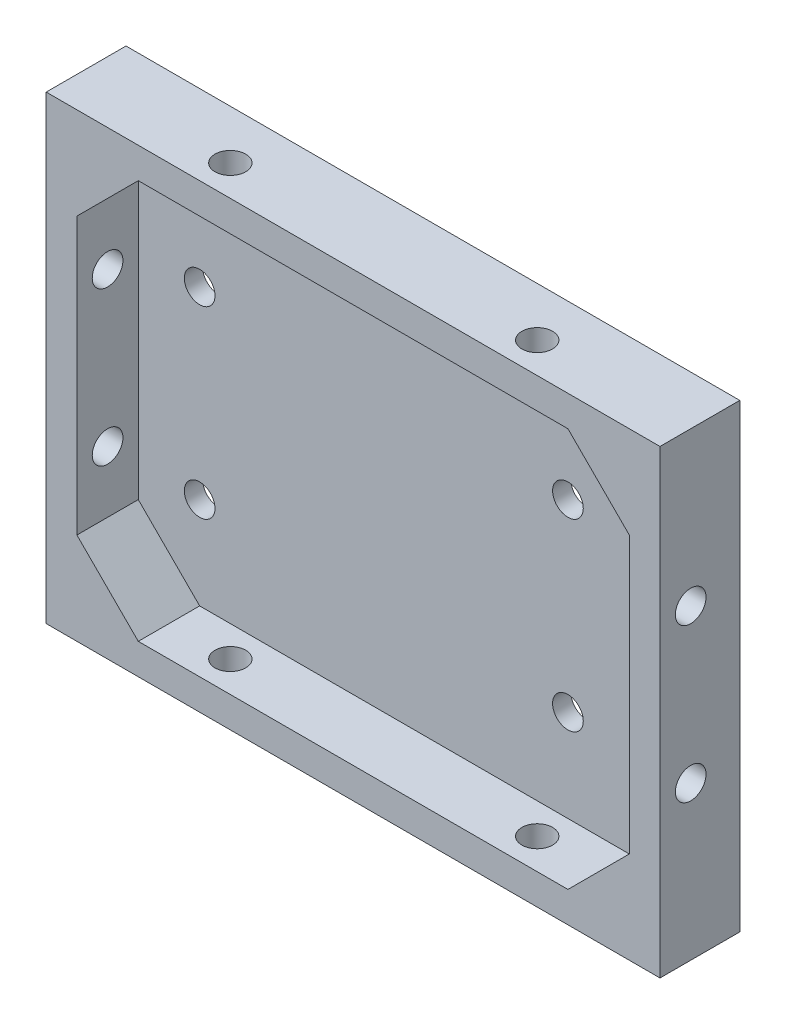
from build123d import *

# Parameters (mm, degrees)
BOSS_EXTRU_1_DEPTH        = 13
COQUE1_T                  = -5
COQUE1_THICKNESS_2_FACE_W = 90
COQUE1_THICKNESS_2_FACE_H = 65
COQUE1_THICKNESS_2_DEPTH  = 2
ENL_V_MAT_EXTRU_1_REACH   = 110.96
ESQUISSE2_R               = 2.5
ENL_V_MAT_EXTRU_2_REACH   = 95.396
ESQUISSE3_R               = 2.5
BOSS_EXTRU_2_DEPTH        = 10
ESQUISSE6_R               = 2.5
ESQUISSE6_R_2             = 5
ENL_V_MAT_EXTRU_3_DEPTH   = 3


with BuildPart() as part:
    # Esquisse1 → Boss.-Extru.1 (new body)
    with BuildSketch(Plane.XY):
        Polygon((44.118436308, 33.728448276), (54.118436308, 33.728448276), (54.118436308, 23.728448276), (54.118436308, -41.271551724), (-45.881563692, -41.271551724), (-45.881563692, 33.728448276), align=None)
    extrude(amount=BOSS_EXTRU_1_DEPTH)

    # Coque1
    coque1_openings = [part.faces().sort_by_distance(p)[0] for p in [
        (4.118436308, -3.771551724, 13),
    ]]
    offset(amount=COQUE1_T, openings=coque1_openings, kind=Kind.INTERSECTION)

    # Coque1 thickness 2 face (on inner face of the shell) → Coque1 thickness 2 (cut)
    with BuildSketch(Plane(origin=(4.118436308, -3.771551724, 5), x_dir=(-1, 0, 0), z_dir=(0, 0, -1))):
        Rectangle(COQUE1_THICKNESS_2_FACE_W, COQUE1_THICKNESS_2_FACE_H)
    extrude(amount=COQUE1_THICKNESS_2_DEPTH, mode=Mode.SUBTRACT)

    # Enlèv. mat.-Extru.1: up to this face of the body (flat: up to its plane)
    enl_v_mat_extru_1_end = Plane(part.part.faces().sort_by_distance((54.118436308, -3.771551724, 6.5))[0])
    # Esquisse2 → Enlèv. mat.-Extru.1 (cut, up to the picked face)
    with BuildSketch(Plane.ZY.offset(45.881563692), mode=Mode.PRIVATE) as enl_v_mat_extru_1_sk1:
        with Locations(Location((8, -16.271551724, 0), (0, 0, 270))):
            Circle(ESQUISSE2_R)
    enl_v_mat_extru_1_tool1 = split(extrude(enl_v_mat_extru_1_sk1.sketch, amount=-ENL_V_MAT_EXTRU_1_REACH, mode=Mode.PRIVATE), bisect_by=enl_v_mat_extru_1_end, keep=Keep.BOTH, mode=Mode.PRIVATE)
    # Esquisse2 → Enlèv. mat.-Extru.1 (cut, up to the picked face)
    with BuildSketch(Plane.ZY.offset(45.881563692), mode=Mode.PRIVATE) as enl_v_mat_extru_1_sk2:
        with Locations(Location((8, 8.728448276, 0), (0, 0, 270))):
            Circle(ESQUISSE2_R)
    enl_v_mat_extru_1_tool2 = split(extrude(enl_v_mat_extru_1_sk2.sketch, amount=-ENL_V_MAT_EXTRU_1_REACH, mode=Mode.PRIVATE), bisect_by=enl_v_mat_extru_1_end, keep=Keep.BOTH, mode=Mode.PRIVATE)
    add(enl_v_mat_extru_1_tool1.solids().sort_by(Axis((-45.881564, -16.271552, 8), (1, 0, 0)))[0], mode=Mode.SUBTRACT)
    add(enl_v_mat_extru_1_tool2.solids().sort_by(Axis((-45.881564, 8.728448, 8), (1, 0, 0)))[0], mode=Mode.SUBTRACT)

    # Enlèv. mat.-Extru.2: up to this face of the body (flat: up to its plane)
    enl_v_mat_extru_2_end = Plane(part.part.faces().sort_by_distance((4.118436308, 33.728448276, 6.5))[0])
    # Esquisse3 → Enlèv. mat.-Extru.2 (cut, up to the picked face)
    with BuildSketch(Plane.XZ.offset(41.271551724), mode=Mode.PRIVATE) as enl_v_mat_extru_2_sk1:
        with Locations(Location((-20.881563692, 8, 0), (0, 0, 270))):
            Circle(ESQUISSE3_R)
    enl_v_mat_extru_2_tool1 = split(extrude(enl_v_mat_extru_2_sk1.sketch, amount=-ENL_V_MAT_EXTRU_2_REACH, mode=Mode.PRIVATE), bisect_by=enl_v_mat_extru_2_end, keep=Keep.BOTH, mode=Mode.PRIVATE)
    # Esquisse3 → Enlèv. mat.-Extru.2 (cut, up to the picked face)
    with BuildSketch(Plane.XZ.offset(41.271551724), mode=Mode.PRIVATE) as enl_v_mat_extru_2_sk2:
        with Locations(Location((29.118436308, 8, 0), (0, 0, 270))):
            Circle(ESQUISSE3_R)
    enl_v_mat_extru_2_tool2 = split(extrude(enl_v_mat_extru_2_sk2.sketch, amount=-ENL_V_MAT_EXTRU_2_REACH, mode=Mode.PRIVATE), bisect_by=enl_v_mat_extru_2_end, keep=Keep.BOTH, mode=Mode.PRIVATE)
    add(enl_v_mat_extru_2_tool1.solids().sort_by(Axis((-20.881564, -41.271552, 8), (0, 1, 0)))[0], mode=Mode.SUBTRACT)
    add(enl_v_mat_extru_2_tool2.solids().sort_by(Axis((29.118436, -41.271552, 8), (0, 1, 0)))[0], mode=Mode.SUBTRACT)

    # Esquisse4 → Boss.-Extru.2 (add)
    with BuildSketch(Plane.XY.offset(3)):
        Polygon((-30.881563692, 28.728448276), (-40.881563692, 18.728448276), (-40.881563692, 28.728448276), align=None)
        Polygon((49.118436308, 28.728448276), (49.118436308, 18.728448276), (39.118436308, 28.728448276), align=None)
        Polygon((49.118436308, -36.271551724), (49.118436308, -26.271551724), (39.118436308, -36.271551724), align=None)
        Polygon((-30.881563692, -36.271551724), (-40.881563692, -26.271551724), (-40.881563692, -36.271551724), align=None)
    extrude(amount=BOSS_EXTRU_2_DEPTH)

    # Esquisse6 → Enlèv. mat.-Extru.3 (cut)
    with BuildSketch(Plane.XY.offset(3)):
        with Locations((-30.881563692, -21.271551724)):
            Circle(ESQUISSE6_R)
        with Locations((29.118436308, -21.271551724)):
            Circle(ESQUISSE6_R)
        with Locations((-30.881563692, 8.728448276)):
            Circle(ESQUISSE6_R)
        with Locations((29.118436308, 8.728448276)):
            Circle(ESQUISSE6_R)
        with Locations((39.118436308, 19.605642263)):
            Circle(ESQUISSE6_R_2)
    extrude(amount=-ENL_V_MAT_EXTRU_3_DEPTH, mode=Mode.SUBTRACT)


solid = part.part
